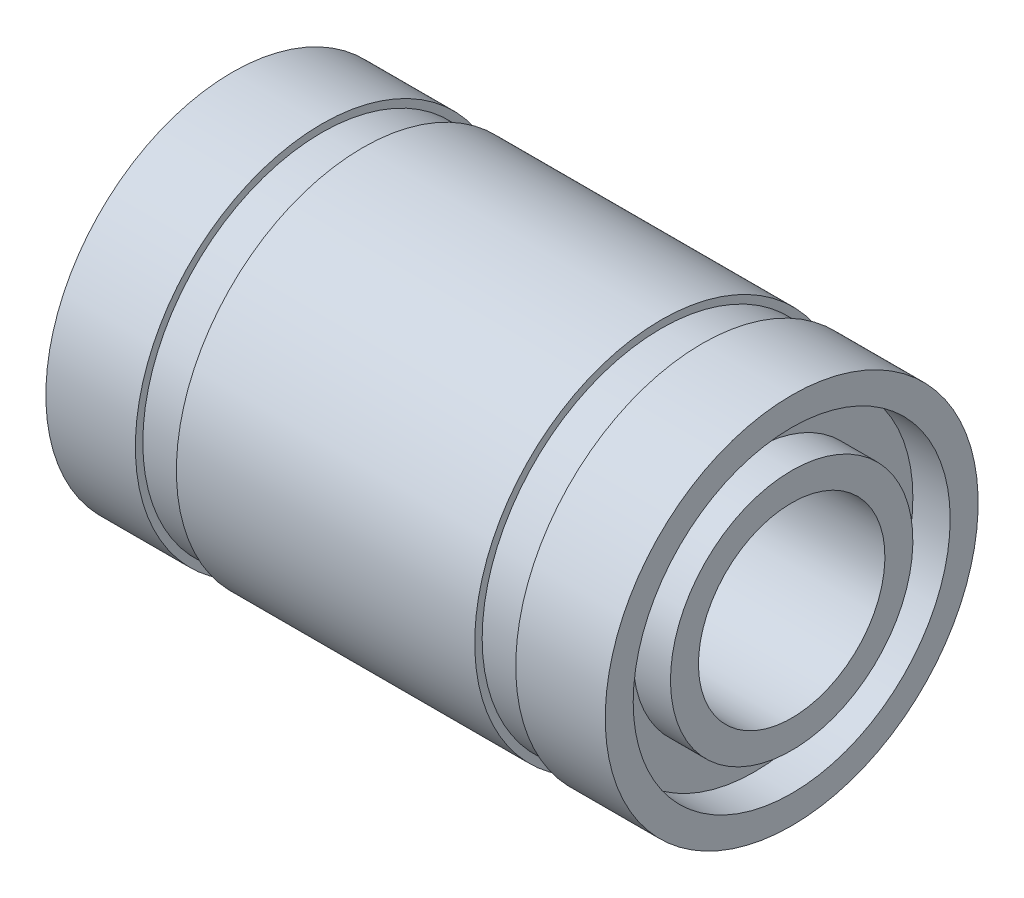
from build123d import *


with BuildPart() as part:
    # Esboço1 → Revolução1 (revolve)
    with BuildSketch(Plane.XY):
        Polygon((-7.5, 5), (-5.1, 5), (-5.1, 4.8), (-4, 4.8), (-4, 5), (4, 5), (4, 4.8), (5.1, 4.8), (5.1, 5), (7.5, 5), (7.5, 4.25), (6.5, 4.25), (6.5, 3.25), (7.5, 3.25), (7.5, 2.5), (-7.5, 2.5), (-7.5, 3.25), (-6.5, 3.25), (-6.5, 4.25), (-7.5, 4.25), align=None)
    revolve(axis=Axis((0, 0, 0), (-1, 0, 0)))


solid = part.part
